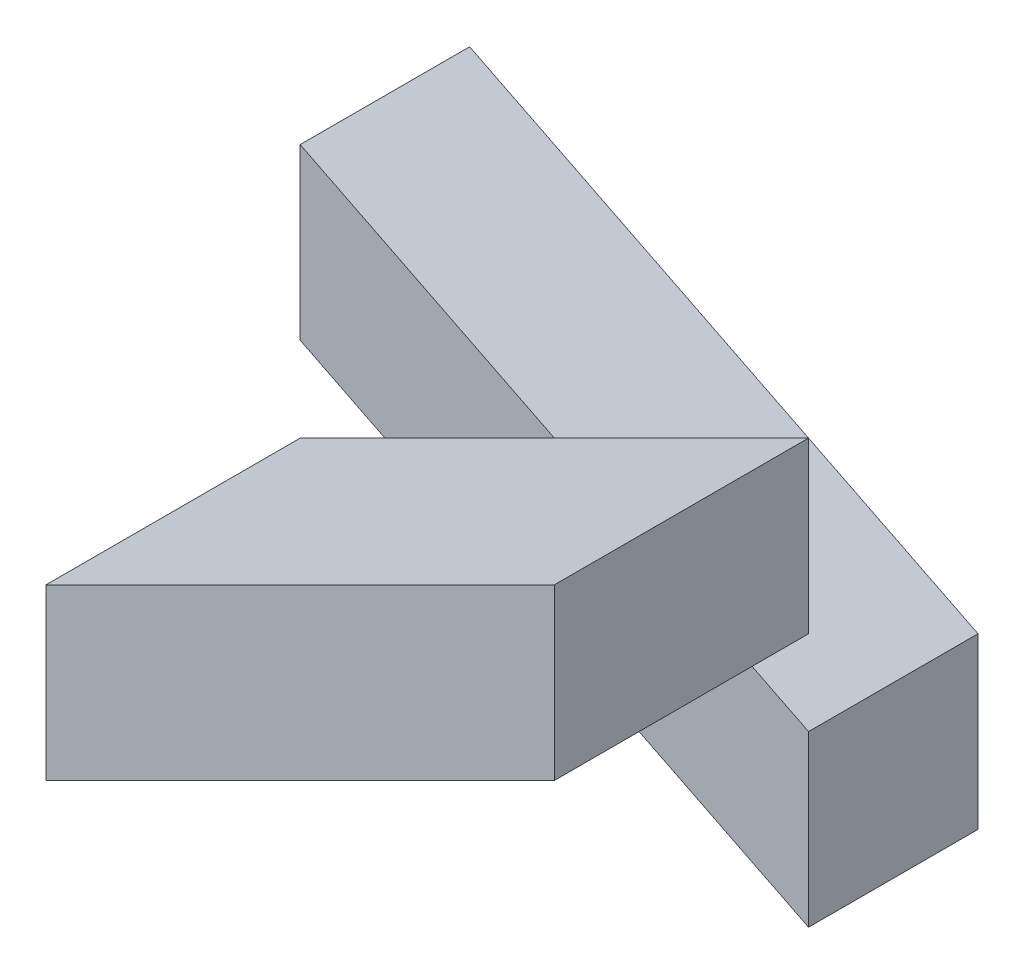
from build123d import *

# Parameters (mm, degrees)
BOSS_EXTRUDE1_DEPTH = 10
BOSS_EXTRUDE3_DEPTH = 15


with BuildPart() as part:
    # Sketch1 → Boss-Extrude1 (new body)
    with BuildSketch(Plane.XY):
        Polygon((-39.908256881, 15.091743119), (-39.908256881, 5.091743119), (-9.908256881, -9.908256881), (-9.908256881, 0.091743119), align=None)
    extrude(amount=BOSS_EXTRUDE1_DEPTH)

    # Sketch2 → Boss-Extrude3 (add)
    with BuildSketch(Plane.XY.offset(10)):
        Polygon((-9.908256881, 15.091743119), (-9.908256881, 5.091743119), (-39.908256881, -9.908256881), (-39.908256881, 0.091743119), align=None)
    extrude(amount=BOSS_EXTRUDE3_DEPTH)


solid = part.part
